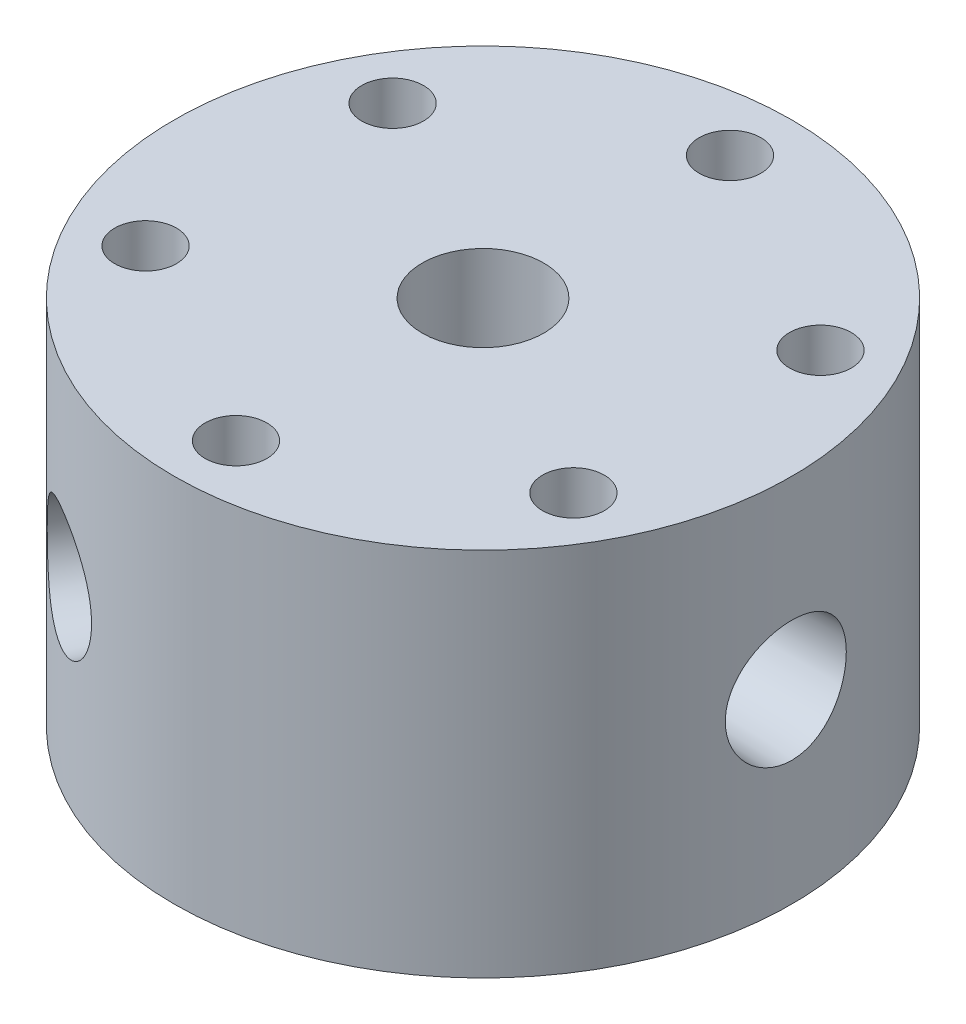
from build123d import *

# Parameters (mm, degrees)
M14X1_5_TAPPED_HOLE1_D              = 12.5
M14X1_5_TAPPED_HOLE1_DEPTH          = 25.4
M14X1_5_TAPPED_HOLE1_TIP            = 3.755378869
F_1_16_0_0625_DIAMETER_HOLE1_D      = 1.5875
F_1_16_0_0625_DIAMETER_HOLE1_DEPTH  = 28.575
F_1_16_0_0625_DIAMETER_HOLE1_TIP    = 0.476933116
F_3_32_0_09375_DIAMETER_HOLE1_D     = 2.38125
F_3_32_0_09375_DIAMETER_HOLE1_DEPTH = 28.702
F_3_32_0_09375_DIAMETER_HOLE1_TIP   = 0.715399675
F_1_4_0_25_DIAMETER_HOLE1_D         = 6.35
CIRPATTERN1_COUNT                   = 6
F_1_32_0_03125_DIAMETER_HOLE2_D     = 0.79375
F_1_32_0_03125_DIAMETER_HOLE2_DEPTH = 28.575
F_1_32_0_03125_DIAMETER_HOLE2_TIP   = 0.238466558


with BuildPart() as part:
    # Sketch1 → Revolve1 (revolve)
    with BuildSketch(Plane.XY):
        Polygon((-6.35, 0), (-31.75, 0), (-31.75, 38.1), (-3.81, 38.1), (-3.81, 6.35), (-6.35, 6.35), align=None)
    revolve(axis=Axis((0, 0, 0), (0, 1, 0)))

    # M14x1.5 Tapped Hole1
    with Locations(Plane(origin=(0, 38.1, 0), x_dir=(1, 0, 0), z_dir=(0, 1, 0))):
        with Locations((0, 0)):
            Hole(M14X1_5_TAPPED_HOLE1_D / 2, depth=M14X1_5_TAPPED_HOLE1_DEPTH)
            with Locations((0, 0, -(M14X1_5_TAPPED_HOLE1_DEPTH + M14X1_5_TAPPED_HOLE1_TIP / 2))):  # 118° drill point
                Cone(0, M14X1_5_TAPPED_HOLE1_D / 2, M14X1_5_TAPPED_HOLE1_TIP, mode=Mode.SUBTRACT)

    # Sketch6 → 1/4 NPT Tapped Hole1 (revolve, cut)
    with BuildSketch(Plane(origin=(31.75, 19.05, 0), x_dir=(0, 0, -1), z_dir=(0, 1, 0))):
        Polygon((0, 0), (0, 20.360347279), (5.5626, 17.018), (5.5626, 9.906), (5.943685794, 9.906), (6.2402847, 0), align=None)
    revolve(axis=Axis((38.1, 19.05, 0), (-1, 0, 0)), mode=Mode.SUBTRACT)

    # Sketch8 → 1/4 NPT Tapped Hole2 (revolve, cut)
    with BuildSketch(Plane(origin=(-31.75, 19.05, 0), x_dir=(0, 0, 1), z_dir=(0, 1, 0))):
        Polygon((0, 0), (0, 20.360347279), (5.5626, 17.018), (5.5626, 9.906), (5.943685794, 9.906), (6.2402847, 0), align=None)
    revolve(axis=Axis((-38.1, 19.05, 0), (1, 0, 0)), mode=Mode.SUBTRACT)

    # 1/16 (0.0625) Diameter Hole1
    with Locations(Plane(origin=(31.75, 0, 0), x_dir=(0, 0, -1), z_dir=(1, 0, 0))):
        with Locations((0, 19.05)):
            Hole(F_1_16_0_0625_DIAMETER_HOLE1_D / 2, depth=F_1_16_0_0625_DIAMETER_HOLE1_DEPTH)
            with Locations((0, 0, -(F_1_16_0_0625_DIAMETER_HOLE1_DEPTH + F_1_16_0_0625_DIAMETER_HOLE1_TIP / 2))):  # 118° drill point
                Cone(0, F_1_16_0_0625_DIAMETER_HOLE1_D / 2, F_1_16_0_0625_DIAMETER_HOLE1_TIP, mode=Mode.SUBTRACT)

    # 3/32 (0.09375) Diameter Hole1
    with Locations(Plane.ZY.offset(31.75)):
        with Locations((0, 19.05)):
            Hole(F_3_32_0_09375_DIAMETER_HOLE1_D / 2, depth=F_3_32_0_09375_DIAMETER_HOLE1_DEPTH)
            with Locations((0, 0, -(F_3_32_0_09375_DIAMETER_HOLE1_DEPTH + F_3_32_0_09375_DIAMETER_HOLE1_TIP / 2))):  # 118° drill point
                Cone(0, F_3_32_0_09375_DIAMETER_HOLE1_D / 2, F_3_32_0_09375_DIAMETER_HOLE1_TIP, mode=Mode.SUBTRACT)

    # 1/4 (0.25) Diameter Hole1 (through all)
    with Locations(Plane(origin=(0, 38.1, 0), x_dir=(1, 0, 0), z_dir=(0, 1, 0))):
        with Locations((21.997045256, 12.7)):
            f_1_4_0_25_diameter_hole1 = Hole(F_1_4_0_25_DIAMETER_HOLE1_D / 2)

    # CirPattern1: 1/4 (0.25) Diameter Hole1 ×6 about axis
    cirpattern1_axis = Axis((0, 0, 0), (0, 1, 0))
    for i in range(1, CIRPATTERN1_COUNT):
        add(f_1_4_0_25_diameter_hole1.rotate(cirpattern1_axis, i * 360 / CIRPATTERN1_COUNT), mode=Mode.SUBTRACT)

    # Sketch18 → 1/4 NPT Tapped Hole3 (revolve, cut)
    with BuildSketch(Plane(origin=(-15.875, 19.05, 27.49630657), x_dir=(0.866025404, 0, 0.5), z_dir=(0, 1, 0))):
        Polygon((0, 0), (0, 19.344347279), (5.5626, 16.002), (5.5626, 9.906), (5.943685794, 9.906), (6.2402847, 0), align=None)
    revolve(axis=Axis((-19.05, 19.05, 32.995567884), (0.5, 0, -0.866025404)), mode=Mode.SUBTRACT)

    # 1/32 (0.03125) Diameter Hole2
    with Locations(Plane(origin=(-15.875, 0, 27.49630657), x_dir=(0, -1, 0), z_dir=(-0.5, 0, 0.866025404))):
        with Locations((-19.05, 0)):
            Hole(F_1_32_0_03125_DIAMETER_HOLE2_D / 2, depth=F_1_32_0_03125_DIAMETER_HOLE2_DEPTH)
            with Locations((0, 0, -(F_1_32_0_03125_DIAMETER_HOLE2_DEPTH + F_1_32_0_03125_DIAMETER_HOLE2_TIP / 2))):  # 118° drill point
                Cone(0, F_1_32_0_03125_DIAMETER_HOLE2_D / 2, F_1_32_0_03125_DIAMETER_HOLE2_TIP, mode=Mode.SUBTRACT)


solid = part.part
